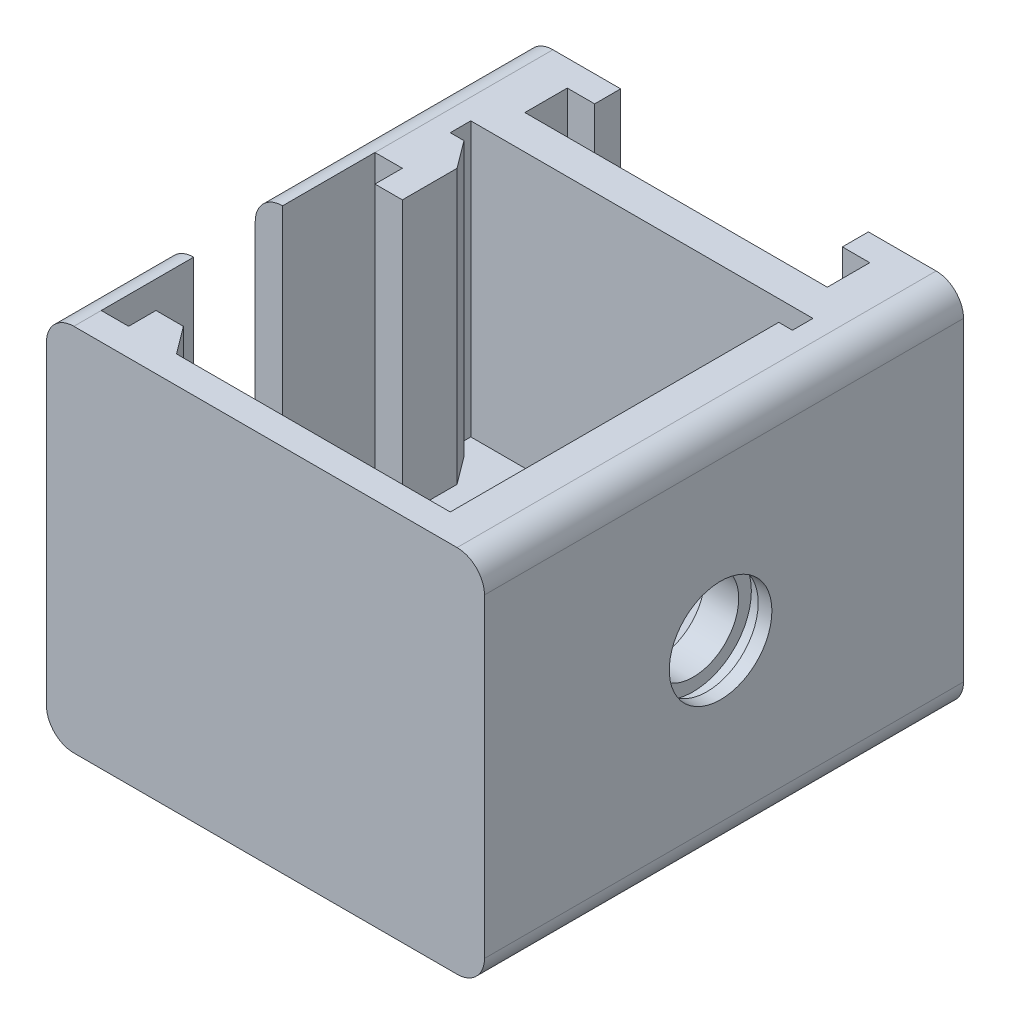
from build123d import *

# Parameters (mm, degrees)
SKETCH1_W               = 32
SKETCH1_H               = 27
BOSS_EXTRUDE1_DEPTH     = 35
FILLET1_R               = 2
CUT_EXTRUDE1_DEPTH      = 1
CUT_EXTRUDE1_DEPTH_BACK = 28
BOSS_EXTRUDE2_DEPTH     = 7
BOSS_EXTRUDE3_DEPTH     = 1.9
SKETCH5_W               = 2
SKETCH5_H               = 7
CUT_EXTRUDE2_DEPTH      = 33
CUT_EXTRUDE3_DEPTH      = 20
SKETCH7_W               = 2
SKETCH7_H               = 33
BOSS_EXTRUDE4_DEPTH     = 0.25
FILLET2_R               = 6
CUT_EXTRUDE5_DEPTH      = 4.5
SKETCH14_W              = 2.5
SKETCH14_H              = 20
CUT_EXTRUDE6_DEPTH      = 20
SKETCH16_W              = 2
SKETCH16_H              = 4
SKETCH16_H_2            = 2
BOSS_EXTRUDE5_DEPTH     = 20
BOSS_EXTRUDE6_DEPTH     = 20


with BuildPart() as part:
    # Sketch1 → Boss-Extrude1 (new body)
    with BuildSketch(Plane.XY):
        Rectangle(SKETCH1_W, SKETCH1_H)
    extrude(amount=BOSS_EXTRUDE1_DEPTH)

    # Fillet1
    fillet1_edges = [part.edges().sort_by_distance(p)[0] for p in [
        (16, -13.5, 17.5),
        (-16, -13.5, 17.5),
        (-16, 13.5, 17.5),
        (16, 13.5, 17.5),
    ]]
    fillet(fillet1_edges, radius=FILLET1_R)

    # Sketch2 → Cut-Extrude1 (cut, two sides)
    with BuildSketch(Plane.XZ.offset(13.5)) as cut_extrude1_sk:
        Polygon((-9.05, 0), (-9.05, 1.9), (-11.05, 1.9), (-11.05, 5), (11.05, 5), (11.05, 1.9), (9.05, 1.9), (9.05, 0), align=None)
    extrude(amount=CUT_EXTRUDE1_DEPTH, mode=Mode.SUBTRACT)
    extrude(cut_extrude1_sk.sketch, amount=-CUT_EXTRUDE1_DEPTH_BACK, mode=Mode.SUBTRACT)

    # Sketch3 → Boss-Extrude2 (add)
    with BuildSketch(Plane.XZ.offset(13.5)):
        Polygon((-9.05, 0), (-9.05, 1.9), (-11.05, 1.9), (-11.05, 5), (11.05, 5), (11.05, 1.9), (9.05, 1.9), (9.05, 0), align=None)
    extrude(amount=-BOSS_EXTRUDE2_DEPTH)

    # Sketch4 → Boss-Extrude3 (add)
    with BuildSketch(Plane(origin=(0, 0, 1.9), x_dir=(-1, 0, 0), z_dir=(0, 0, -1))):
        with BuildLine():
            Line((-9.05, 6.5), (-9.05, 5.5))
            ThreePointArc((-9.05, 5.5), (-8.8, 6), (-9.05, 6.5))
        make_face()
    boss_extrude3 = extrude(amount=BOSS_EXTRUDE3_DEPTH)

    # Mirror1: Boss-Extrude3 across plane
    add(boss_extrude3.mirror(Plane(origin=(0, 0, 0), x_dir=(0, 0, 1), z_dir=(1, 0, 0))))

    # Sketch5 → Cut-Extrude2 (cut)
    with BuildSketch(Plane(origin=(0, 0, 0), x_dir=(-1, 0, 0), z_dir=(0, 0, -1))):
        with Locations((0, -10)):
            Rectangle(SKETCH5_W, SKETCH5_H)
    extrude(amount=-CUT_EXTRUDE2_DEPTH, mode=Mode.SUBTRACT)

    # Sketch6 → Cut-Extrude3 (cut)
    with BuildSketch(Plane(origin=(0, 13.5, 0), x_dir=(1, 0, 0), z_dir=(0, 1, 0))):
        Polygon((-12.5, -7.5), (-12.5, -9), (-11.5, -9), (-11.5, -33), (11.5, -33), (11.5, -9), (12.5, -9), (12.5, -7.5), align=None)
    extrude(amount=-CUT_EXTRUDE3_DEPTH, mode=Mode.SUBTRACT)

    # Sketch7 → Boss-Extrude4 (add)
    with BuildSketch(Plane.XZ.offset(13.5)):
        with Locations((0, 16.5)):
            Rectangle(SKETCH7_W, SKETCH7_H)
    extrude(amount=-BOSS_EXTRUDE4_DEPTH)

    # Fillet2
    fillet2_edges = [part.edges().sort_by_distance(p)[0] for p in [
        (0, -13.25, 33),
    ]]
    fillet(fillet2_edges, radius=FILLET2_R)

    # Sketch9 → Cut-Revolve1 (revolve, cut)
    with BuildSketch(Plane(origin=(0, 0, 17.75), x_dir=(-1, 0, 0), z_dir=(0, 0, -1))):
        Polygon((-15, 4.25), (-14, 4.25), (-14, 3.325), (-11.5, 3.325), (-11.5, 0), (-16, 0), (-16, 3.75), (-15, 3.75), align=None)
    revolve(axis=Axis((16, 0, 17.75), (-1, 0, 0)), mode=Mode.SUBTRACT)

    # Sketch11 → Cut-Extrude5 (cut)
    with BuildSketch(Plane(origin=(-16, 0, 44), x_dir=(0, 0, -1), z_dir=(1, 0, 0))):
        with BuildLine():
            Line((24.25, 23), (24.25, 0))
            ThreePointArc((24.25, 0), (21, -3.25), (17.75, 0))
            Line((17.75, 0), (17.75, 23))
            ThreePointArc((17.75, 23), (21, 26.25), (24.25, 23))
        make_face()
    extrude(amount=CUT_EXTRUDE5_DEPTH, mode=Mode.SUBTRACT)

    # Sketch14 → Cut-Extrude6 (cut)
    with BuildSketch(Plane(origin=(0, 13.5, 0), x_dir=(1, 0, 0), z_dir=(0, 1, 0))):
        with Locations((-12.75, -23)):
            Rectangle(SKETCH14_W, SKETCH14_H)
    extrude(amount=-CUT_EXTRUDE6_DEPTH, mode=Mode.SUBTRACT)

    # Sketch16 → Boss-Extrude5 (add)
    with BuildSketch(Plane(origin=(0, 13.5, 0), x_dir=(1, 0, 0), z_dir=(0, 1, 0))):
        with Locations((-11, -13)):
            Rectangle(SKETCH16_W, SKETCH16_H)
        with Locations((-11, -32)):
            Rectangle(SKETCH16_W, SKETCH16_H_2)
    extrude(amount=-BOSS_EXTRUDE5_DEPTH)

    # Sketch20 → Boss-Extrude6 (add)
    with BuildSketch(Plane(origin=(0, 13.5, 0), x_dir=(1, 0, 0), z_dir=(0, 1, 0))):
        Polygon((-11.5, -9), (-10, -11), (-11.5, -11), align=None)
        Polygon((-10, -31), (-8.5, -33), (-10, -33), align=None)
    extrude(amount=-BOSS_EXTRUDE6_DEPTH)


solid = part.part
